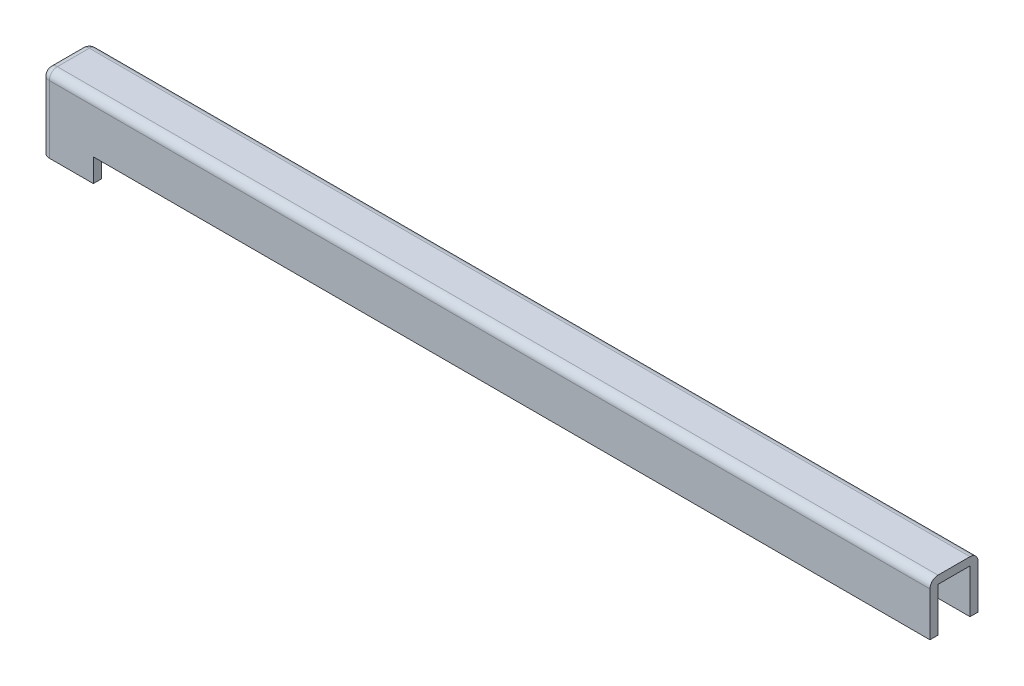
from build123d import *

# Parameters (mm, degrees)
BOSS_EXTRUDE1_DEPTH = 220
SKETCH2_W           = 12
SKETCH2_H           = 13
BOSS_EXTRUDE2_DEPTH = 2
BOSS_EXTRUDE3_DEPTH = 5.8
FILLET1_R           = 2


with BuildPart() as part:
    # Sketch1 → Boss-Extrude1 (new body)
    with BuildSketch(Plane(origin=(0, 0, 0), x_dir=(0, 0, -1), z_dir=(1, 0, 0))):
        Polygon((8, 0), (8, 11), (0, 11), (0, 0), (-2, 0), (-2, 13), (10, 13), (10, 0), align=None)
    extrude(amount=BOSS_EXTRUDE1_DEPTH)

    # Sketch2 → Boss-Extrude2 (add)
    with BuildSketch(Plane.ZY):
        with Locations((-4, 6.5)):
            Rectangle(SKETCH2_W, SKETCH2_H)
    extrude(amount=BOSS_EXTRUDE2_DEPTH)

    # Sketch4 → Boss-Extrude3 (add)
    with BuildSketch(Plane.XZ):
        Polygon((0, 0), (11, 0), (11, 2), (-2, 2), (-2, -10), (11, -10), (11, -8), (0, -8), align=None)
    extrude(amount=BOSS_EXTRUDE3_DEPTH)

    # Fillet1
    fillet1_edges = [part.edges().sort_by_distance(p)[0] for p in [
        (109, 13, 2),
        (109, 13, -10),
        (-2, 3.6, -10),
        (-2, 3.6, 2),
        (-2, 13, -4),
    ]]
    fillet(fillet1_edges, radius=FILLET1_R)


solid = part.part
